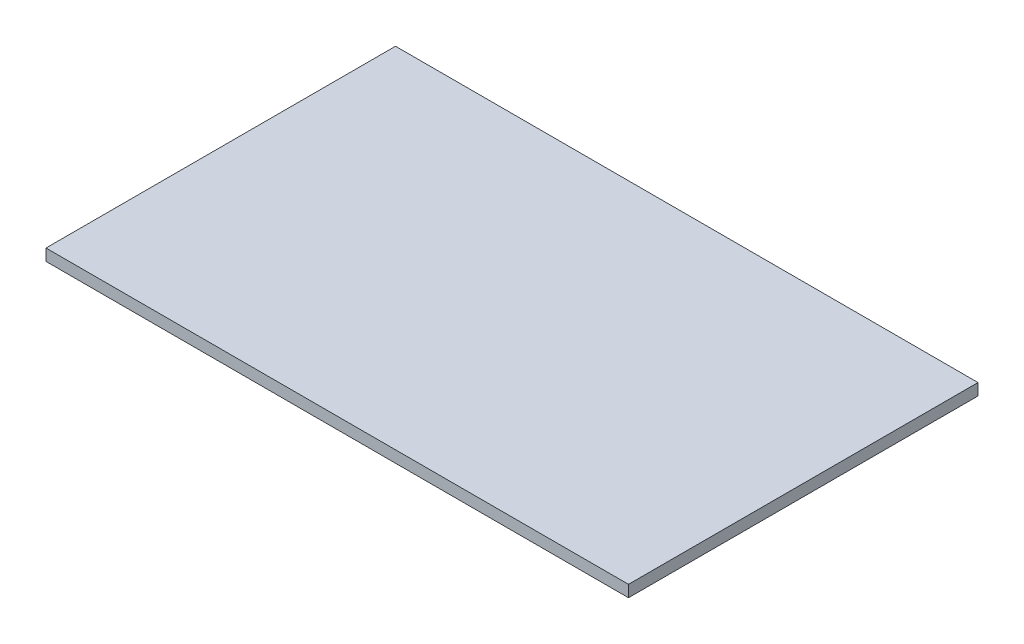
from build123d import *

# Parameters (mm, degrees)
SKETCH1_W           = 300
SKETCH1_H           = 180
BOSS_EXTRUDE1_DEPTH = 6


with BuildPart() as part:
    # Sketch1 → Boss-Extrude1 (new body)
    with BuildSketch(Plane(origin=(0, 0, 0), x_dir=(1, 0, 0), z_dir=(0, 1, 0))):
        with Locations((150, 90)):
            Rectangle(SKETCH1_W, SKETCH1_H)
    extrude(amount=BOSS_EXTRUDE1_DEPTH)


solid = part.part
